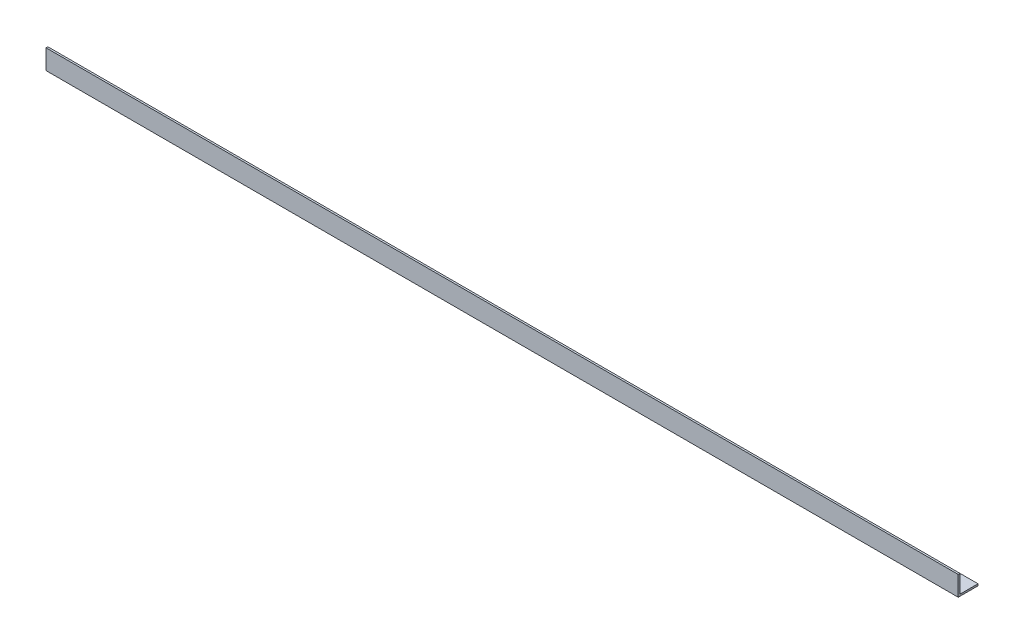
from build123d import *

# Parameters (mm, degrees)
EXTRUDE_1_DEPTH = 3000


with BuildPart() as part:
    # Эскиз1 → Вытянуть-Тонкостенный1 (new body)
    with BuildSketch(Plane(origin=(0, 0, 0), x_dir=(0, 0, -1), z_dir=(1, 0, 0))):
        Polygon((0, 65), (0, 0), (65, 0), (65, 6), (6, 6), (6, 65), align=None)
    extrude(amount=EXTRUDE_1_DEPTH)


solid = part.part
